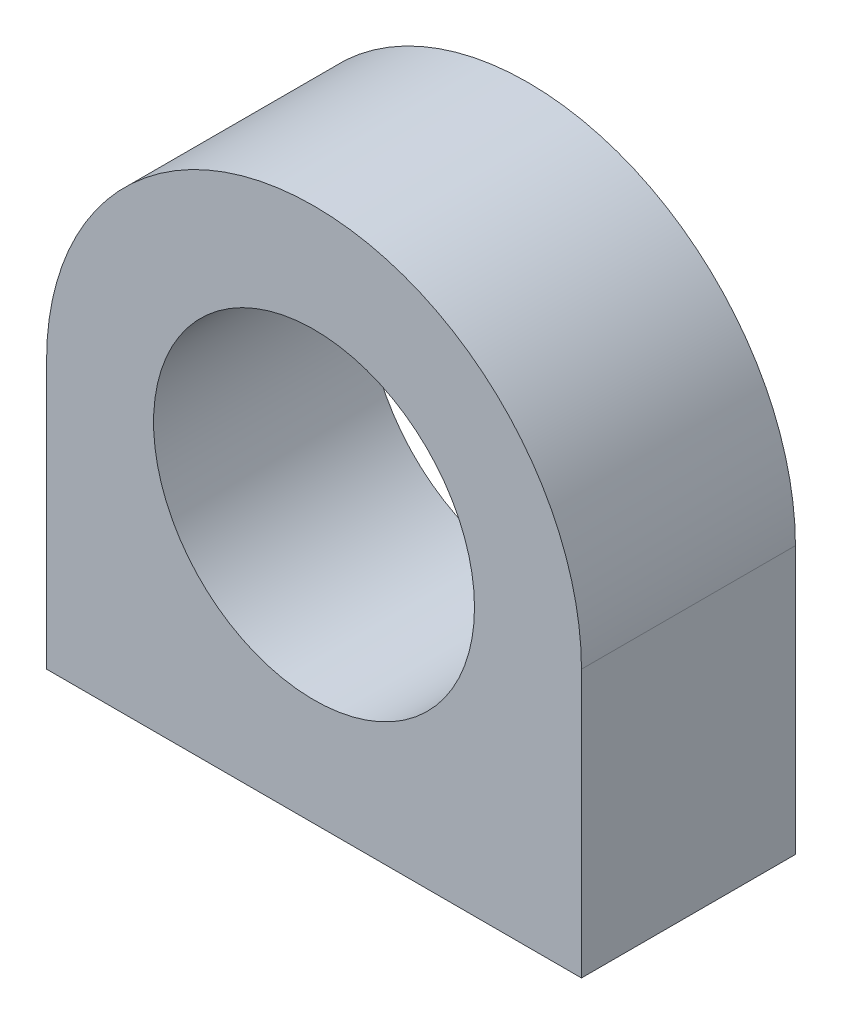
from build123d import *

# Parameters (mm, degrees)
SKETCH1_R           = 3
BOSS_EXTRUDE1_DEPTH = 4


with BuildPart() as part:
    # Sketch1 → Boss-Extrude1 (new body)
    with BuildSketch(Plane.XY):
        with BuildLine():
            Line((-5, -2.5), (5, -2.5))
            Line((5, -2.5), (5, 2.5))
            ThreePointArc((5, 2.5), (0, 7.5), (-5, 2.5))
            Line((-5, 2.5), (-5, -2.5))
        make_face()
        with Locations((0, 2.5)):
            Circle(SKETCH1_R, mode=Mode.SUBTRACT)
    extrude(amount=BOSS_EXTRUDE1_DEPTH)


solid = part.part
